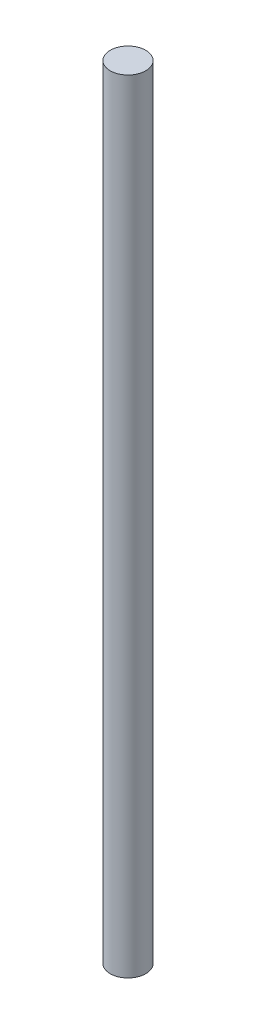
from build123d import *

# Parameters (mm, degrees)
ESBO_O1_R                = 2.5
RESSALTO_EXTRUS_O1_DEPTH = 110


with BuildPart() as part:
    # Esboço1 → Ressalto-extrusão1 (new body)
    with BuildSketch(Plane(origin=(0, 0, 0), x_dir=(1, 0, 0), z_dir=(0, 1, 0))):
        Circle(ESBO_O1_R)
    extrude(amount=RESSALTO_EXTRUS_O1_DEPTH)


solid = part.part
